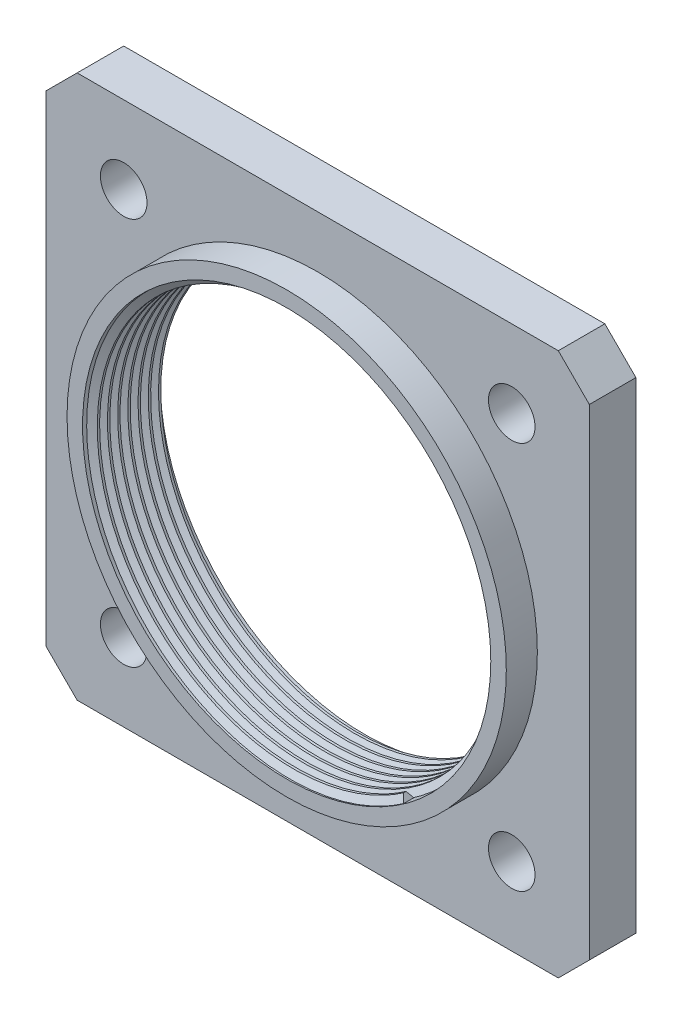
from build123d import *

# Parameters (mm, degrees)
SKETCH1_W           = 35
SKETCH1_H           = 35
SKETCH1_R           = 1.5
SKETCH1_R_2         = 13.15
BOSS_EXTRUDE1_DEPTH = 3
SKETCH3_R           = 14.15
SKETCH3_R_2         = 13.15
BOSS_EXTRUDE2_DEPTH = 2
CHAMFER1_SIZE       = 2
SWEEP1_PITCH        = 0.657225
SWEEP1_HEIGHT       = 4.5
SWEEP1_RADIUS       = 13.145
SKETCH6_R           = 26.617101451
CUT_EXTRUDE1_DEPTH  = 1.172278619


with BuildPart() as part:
    # Sketch1 → Boss-Extrude1 (new body)
    with BuildSketch(Plane.XY):
        Rectangle(SKETCH1_W, SKETCH1_H)
        with Locations((-12.5, 12.5)):
            Circle(SKETCH1_R, mode=Mode.SUBTRACT)
        with Locations((12.5, 12.5)):
            Circle(SKETCH1_R, mode=Mode.SUBTRACT)
        with Locations((-12.5, -12.5)):
            Circle(SKETCH1_R, mode=Mode.SUBTRACT)
        with Locations((12.5, -12.5)):
            Circle(SKETCH1_R, mode=Mode.SUBTRACT)
        Circle(SKETCH1_R_2, mode=Mode.SUBTRACT)
    extrude(amount=BOSS_EXTRUDE1_DEPTH)

    # Sketch3 → Boss-Extrude2 (add)
    with BuildSketch(Plane.XY.offset(3)):
        Circle(SKETCH3_R)
        Circle(SKETCH3_R_2, mode=Mode.SUBTRACT)
    extrude(amount=BOSS_EXTRUDE2_DEPTH)

    # Chamfer1
    chamfer1_edges = [part.edges().sort_by_distance(p)[0] for p in [
        (17.5, -17.5, 1.5),
        (-17.5, -17.5, 1.5),
        (-17.5, 17.5, 1.5),
        (17.5, 17.5, 1.5),
    ]]
    chamfer(chamfer1_edges, length=CHAMFER1_SIZE)


with BuildPart() as body_2:
    # Sweep1: sweep along a helix
    with BuildLine() as sweep1_path:
        Helix(SWEEP1_PITCH, SWEEP1_HEIGHT, SWEEP1_RADIUS, center=(0, 0, 0), direction=(0, 0, 1))
    # Sketch5 → Sweep1 (sweep)
    with BuildSketch(Plane(origin=(7.522603109, -10.779678449, 4.5), x_dir=(0.006525369, 0.004553732, -0.999968341), z_dir=(0.820033258, 0.572260552, 0.007957193))):
        Polygon((-0.227716027, 0.443383435), (-0.077716027, 0.443383435), (0.172283973, 0.010370734), (-0.477716027, 0.010370734), align=None)
    sweep(path=sweep1_path.line, is_frenet=True)

    # Sketch6 → Cut-Extrude1 (cut, through all)
    with BuildSketch(Plane(origin=(0, 0, 0), x_dir=(-1, 0, 0), z_dir=(0, 0, -1))):
        Circle(SKETCH6_R)
    extrude(amount=CUT_EXTRUDE1_DEPTH, mode=Mode.SUBTRACT)


solid = Compound([part.part, body_2.part])
